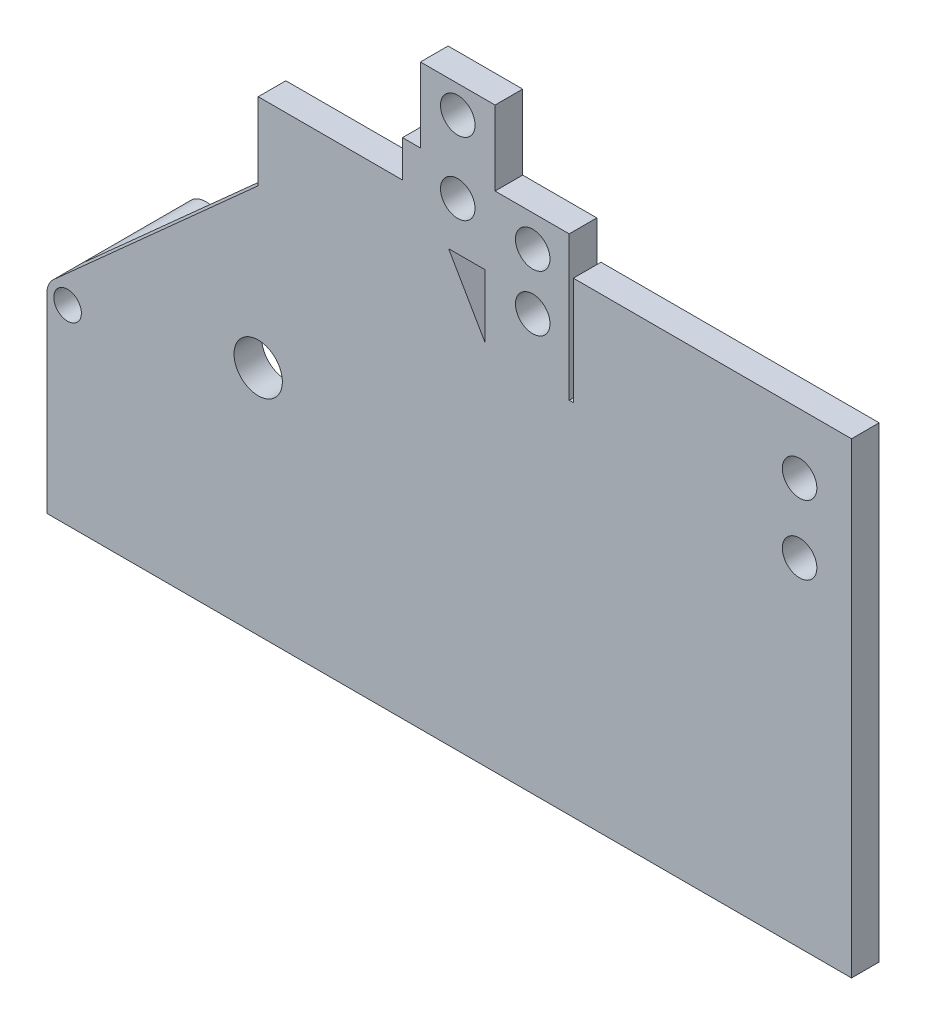
from build123d import *

# Parameters (mm, degrees)
SKETCH1_R            = 17.5
SKETCH1_R_2          = 10
BOSS_EXTRUDE1_DEPTH  = 20
SKETCH2_R            = 15
SKETCH2_R_2          = 10
BOSS_EXTRUDE2_DEPTH  = 100
BOSS_EXTRUDE6_DEPTH  = 20
BOSS_EXTRUDE7_DEPTH  = 20
SKETCH10_R           = 12.5
BOSS_EXTRUDE9_DEPTH  = 20
BOSS_EXTRUDE10_DEPTH = 20
SKETCH16_R           = 12.5
CUT_EXTRUDE1_DEPTH   = 20


with BuildPart() as part:
    # Sketch1 → Boss-Extrude1 (new body)
    with BuildSketch(Plane.XY):
        with BuildLine():
            Line((0, 138), (0, 0))
            Line((0, 0), (582.5, 0))
            Line((582.5, 0), (582.5, 51.183651))
            Line((582.5, 51.183651), (572.5, 51.183651))
            Line((572.5, 51.183651), (374.6494, 86.07005))
            Line((374.6494, 86.07005), (244.94, 310.733321))
            ThreePointArc((244.94, 310.733321), (200.912249, 330.84879), (153, 337.740187))
            Line((153, 337.740187), (153, 281.918848))
            Line((153, 281.918848), (4.984782, 149.16671))
            ThreePointArc((4.984782, 149.16671), (1.302769, 144.114398), (0, 138))
        make_face()
        with Locations((153, 167.740187)):
            Circle(SKETCH1_R, mode=Mode.SUBTRACT)
        with Locations((15, 138)):
            Circle(SKETCH1_R_2, mode=Mode.SUBTRACT)
    extrude(amount=BOSS_EXTRUDE1_DEPTH)

    # Sketch2 → Boss-Extrude2 (add)
    with BuildSketch(Plane.XY.offset(20)):
        with Locations((15, 138)):
            Circle(SKETCH2_R)
        with Locations((15, 138)):
            Circle(SKETCH2_R_2, mode=Mode.SUBTRACT)
    extrude(amount=-BOSS_EXTRUDE2_DEPTH)

    # Sketch4 → Boss-Extrude6 (add)
    with BuildSketch(Plane.XY.offset(20)):
        with BuildLine():
            Line((257.460496, 337.740187), (153, 337.740187))
            ThreePointArc((153, 337.740187), (200.912249, 330.84879), (244.94, 310.733321))
            Line((244.94, 310.733321), (374.6494, 86.07005))
            Line((374.6494, 86.07005), (426.173106, 76.98503))
            Line((426.173106, 76.98503), (290.842774, 311.384043))
            Line((290.842774, 311.384043), (257.460496, 311.384043))
            Line((257.460496, 311.384043), (257.460496, 337.740187))
        make_face()
    extrude(amount=-BOSS_EXTRUDE6_DEPTH)

    # Sketch9 → Boss-Extrude7 (add)
    with BuildSketch(Plane.XY.offset(20)):
        Polygon((320.509364, 260), (522.5, 260), (582.5, 260), (582.5, 51.183651), (572.5, 51.183651), (522.5, 60), (426.173106, 76.98503), align=None)
    extrude(amount=-BOSS_EXTRUDE7_DEPTH)



with BuildPart() as body_2:
    # Sketch10 → Boss-Extrude9 (new body)
    with BuildSketch(Plane.XY.offset(20)):
        Polygon((270.460496, 418.251615), (270.460496, 364.320187), (317.180522, 364.320187), (324.460496, 364.320187), (324.460496, 418.251615), align=None)
        with Locations((297.460496, 398.384043)):
            Circle(SKETCH10_R, mode=Mode.SUBTRACT)
        Polygon((270.460496, 364.320187), (257.460496, 364.320187), (257.460496, 337.740187), (257.460496, 311.384043), (290.842774, 311.384043), (317.180522, 311.384043), (317.180522, 321.223855), (317.180522, 364.320187), align=None)
        with Locations((297.460496, 346.134043)):
            Circle(SKETCH10_R, mode=Mode.SUBTRACT)
        Polygon((324.460496, 364.320187), (317.180522, 364.320187), (317.180522, 321.223855), (347.650509, 321.223855), (378.120496, 321.223855), (378.120496, 364.320187), align=None)
        with Locations((351.710496, 341.56)):
            Circle(SKETCH10_R, mode=Mode.SUBTRACT)
        Polygon((347.650509, 321.223855), (317.180522, 321.223855), (317.180522, 311.384043), (317.180522, 265.765724), (320.509364, 260), (378.120496, 260), (378.120496, 321.223855), align=None)
        with Locations((351.710496, 301)):
            Circle(SKETCH10_R, mode=Mode.SUBTRACT)
    extrude(amount=-BOSS_EXTRUDE9_DEPTH)


with BuildPart() as part_1:
    add(part.part)

    add(body_2.part)  # Boss-Extrude10 merges body 2
    # Sketch14 → Boss-Extrude10 (add)
    with BuildSketch(Plane(origin=(0, 0, 0), x_dir=(-1, 0, 0), z_dir=(0, 0, -1))):
        Polygon((-320.509364, 260), (-426.173106, 76.98503), (-522.5, 60), (-572.5, 60), (-582.5, 60), (-582.5, 338.045557), (-522.5, 338.045557), (-381.119364, 338.045557), (-381.119364, 260), align=None)
    extrude(amount=-BOSS_EXTRUDE10_DEPTH)

    # Sketch16 → Cut-Extrude1 (cut)
    with BuildSketch(Plane.XY.offset(20)):
        with Locations((544.895661, 294.516191)):
            Circle(SKETCH16_R)
        with Locations((544.895661, 244.516191)):
            Circle(SKETCH16_R)
    extrude(amount=-CUT_EXTRUDE1_DEPTH, mode=Mode.SUBTRACT)


solid = part_1.part
